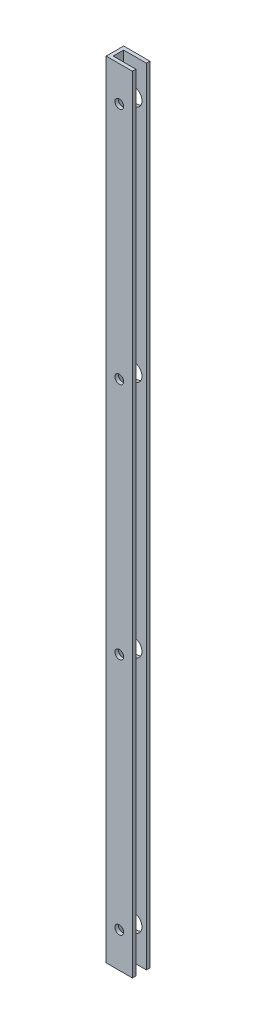
from build123d import *

# Parameters (mm, degrees)
BOSS_EXTRUDE1_DEPTH = 285.75
SKETCH2_R           = 1.27
CUT_EXTRUDE1_DEPTH  = 20.05
SKETCH4_R           = 3.175
CUT_EXTRUDE2_DEPTH  = 140.208
SKETCH5_R           = 6.35
CUT_EXTRUDE3_DEPTH  = 2.54


with BuildPart() as part:
    # Sketch1 → Boss-Extrude1 (new body, symmetric)
    with BuildSketch(Plane(origin=(0, 0, 0), x_dir=(1, 0, 0), z_dir=(0, 1, 0))):
        Polygon((19.05, 3.81), (19.05, 6.35), (0, 6.35), (0, -6.35), (19.05, -6.35), (19.05, -3.81), (2.54, -3.81), (2.54, 3.81), align=None)
    extrude(amount=BOSS_EXTRUDE1_DEPTH, both=True)

    # Sketch2 → Cut-Extrude1 (cut, through all)
    with BuildSketch(Plane.ZY):
        with Locations((-0.286445318, 279.4)):
            Circle(SKETCH2_R)
        with Locations((-0.286445318, 222.25)):
            Circle(SKETCH2_R)
        with Locations((-0.286445318, 165.1)):
            Circle(SKETCH2_R)
        with Locations((-0.286445318, 107.95)):
            Circle(SKETCH2_R)
        with Locations((-0.286445318, 50.8)):
            Circle(SKETCH2_R)
        with Locations((-0.286445318, -6.35)):
            Circle(SKETCH2_R)
        with Locations((-0.286445318, -63.5)):
            Circle(SKETCH2_R)
        with Locations((-0.286445318, -120.65)):
            Circle(SKETCH2_R)
        with Locations((-0.286445318, -177.8)):
            Circle(SKETCH2_R)
        with Locations((-0.286445318, -234.95)):
            Circle(SKETCH2_R)
    extrude(amount=-CUT_EXTRUDE1_DEPTH, mode=Mode.SUBTRACT)

    # Sketch4 → Cut-Extrude2 (cut)
    with BuildSketch(Plane(origin=(0, 0, 3.81), x_dir=(-1, 0, 0), z_dir=(0, 0, -1))):
        with Locations((-9.525, 260.35)):
            Circle(SKETCH4_R)
        with Locations((-9.525, 86.868)):
            Circle(SKETCH4_R)
        with Locations((-9.525, -86.614)):
            Circle(SKETCH4_R)
        with Locations((-9.525, -260.096)):
            Circle(SKETCH4_R)
    extrude(amount=-CUT_EXTRUDE2_DEPTH, mode=Mode.SUBTRACT)

    # Sketch5 → Cut-Extrude3 (cut)
    with BuildSketch(Plane(origin=(0, 0, -6.35), x_dir=(-1, 0, 0), z_dir=(0, 0, -1))):
        with Locations((-9.525, 260.35)):
            Circle(SKETCH5_R)
        with Locations((-9.525, 86.7918)):
            Circle(SKETCH5_R)
        with Locations((-9.525, -86.7664)):
            Circle(SKETCH5_R)
        with Locations((-9.525, -260.3246)):
            Circle(SKETCH5_R)
    extrude(amount=-CUT_EXTRUDE3_DEPTH, mode=Mode.SUBTRACT)


solid = part.part
